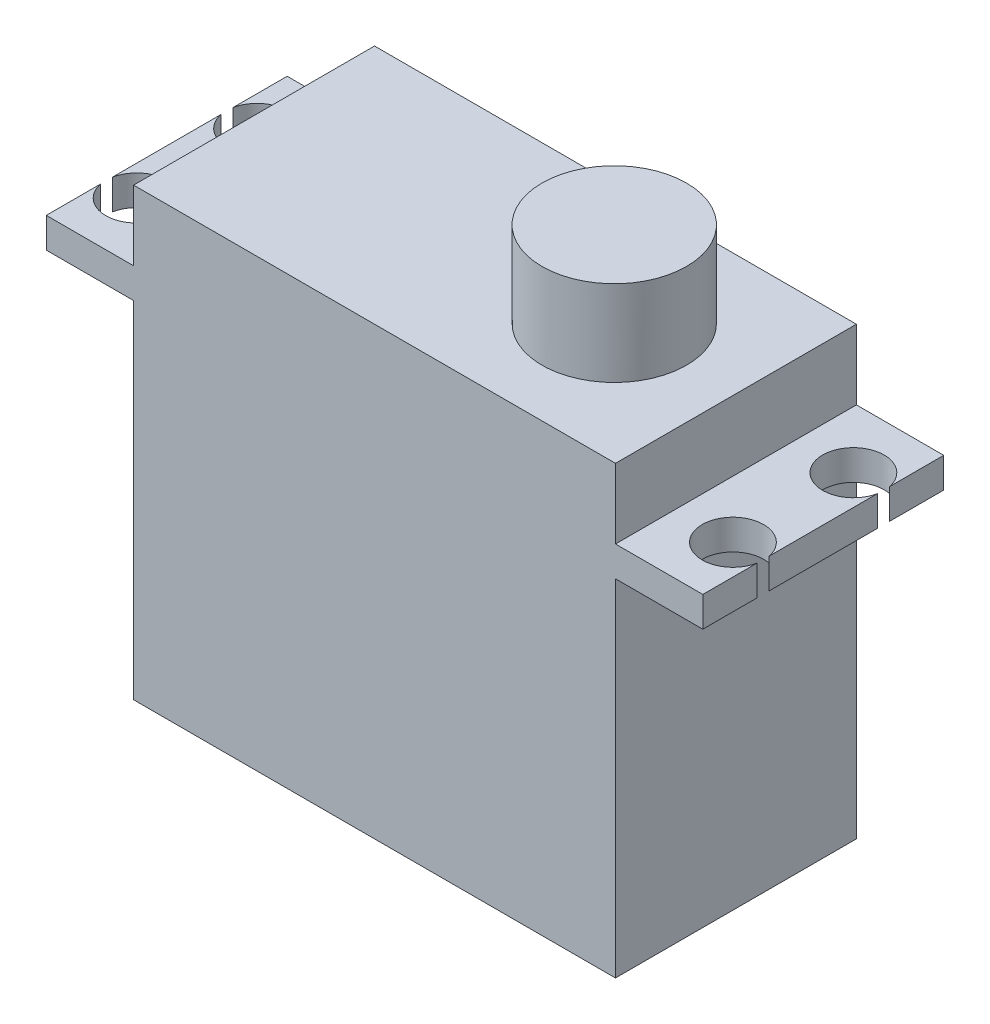
from build123d import *

# Parameters (mm, degrees)
SKETCH1_W           = 40
SKETCH1_H           = 20
BOSS_EXTRUDE1_DEPTH = 28.7
SKETCH2_W           = 54.5
SKETCH2_H           = 20
BOSS_EXTRUDE2_DEPTH = 2.5
SKETCH3_W           = 40
SKETCH3_H           = 20
BOSS_EXTRUDE3_DEPTH = 5.8
SKETCH4_R           = 6
BOSS_EXTRUDE4_DEPTH = 7.1
SKETCH5_R           = 2.55
CUT_EXTRUDE3_DEPTH  = 7.1


with BuildPart() as part:
    # Sketch1 → Boss-Extrude1 (new body)
    with BuildSketch(Plane(origin=(0, 0, 0), x_dir=(1, 0, 0), z_dir=(0, 1, 0))):
        Rectangle(SKETCH1_W, SKETCH1_H)
    extrude(amount=BOSS_EXTRUDE1_DEPTH)

    # Sketch2 → Boss-Extrude2 (add)
    with BuildSketch(Plane(origin=(0, 28.7, 0), x_dir=(1, 0, 0), z_dir=(0, 1, 0))):
        Rectangle(SKETCH2_W, SKETCH2_H)
    extrude(amount=BOSS_EXTRUDE2_DEPTH)

    # Sketch3 → Boss-Extrude3 (add)
    with BuildSketch(Plane(origin=(0, 31.2, 0), x_dir=(1, 0, 0), z_dir=(0, 1, 0))):
        Rectangle(SKETCH3_W, SKETCH3_H)
    extrude(amount=BOSS_EXTRUDE3_DEPTH)

    # Sketch4 → Boss-Extrude4 (add)
    with BuildSketch(Plane(origin=(0, 37, 0), x_dir=(1, 0, 0), z_dir=(0, 1, 0))):
        with Locations((9.9, 0)):
            Circle(SKETCH4_R)
    extrude(amount=BOSS_EXTRUDE4_DEPTH)

    # Sketch5 → Cut-Extrude3 (cut)
    with BuildSketch(Plane(origin=(0, 31.2, 0), x_dir=(1, 0, 0), z_dir=(0, 1, 0))):
        with Locations((-24.75, 5)):
            Circle(SKETCH5_R)
        with Locations((-24.75, -5)):
            Circle(SKETCH5_R)
        with Locations((24.75, -5)):
            Circle(SKETCH5_R)
        with Locations((24.75, 5)):
            Circle(SKETCH5_R)
    extrude(amount=-CUT_EXTRUDE3_DEPTH, mode=Mode.SUBTRACT)


solid = part.part
